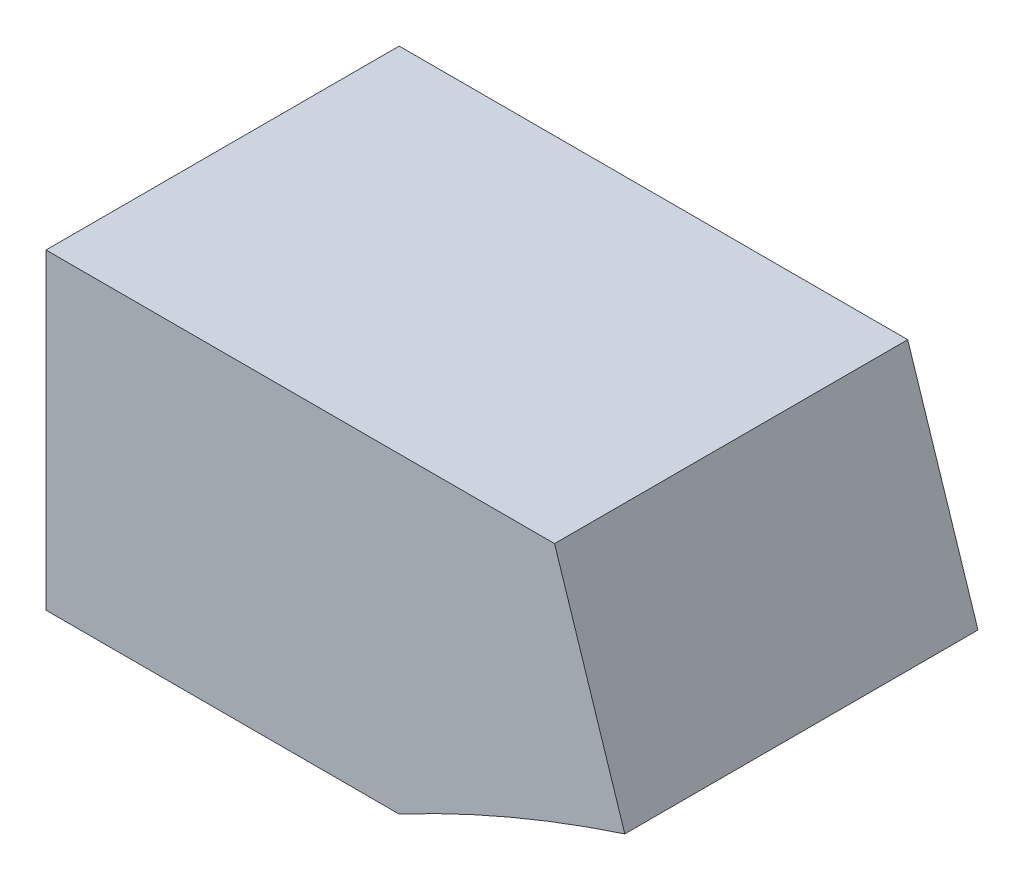
from build123d import *

# Parameters (mm, degrees)
EXTRUDE_1_DEPTH = 480
SCALE_1_SCALE   = 1.3


with BuildPart() as part:
    # 草图1 → 凸台-拉伸1 (new body)
    with BuildSketch(Plane.XY):
        with BuildLine():
            Line((-7619.991111067, 5536), (-7139.991111067, 5536))
            ThreePointArc((-7139.991111067, 5536), (-6989.477063432, 5607.677609574), (-6833.3126292, 5666.028511287))
            Line((-6833.3126292, 5666.028511287), (-6928.829756014, 5960))
            Line((-6928.829756014, 5960), (-7619.991111067, 5960))
            Line((-7619.991111067, 5960), (-7619.991111067, 5536))
        make_face()
    extrude(amount=EXTRUDE_1_DEPTH)


with BuildPart() as part_1:
    # 缩放比例1: scaled about (0, 0, 0)
    add(part.part.scale(SCALE_1_SCALE))


solid = part_1.part
